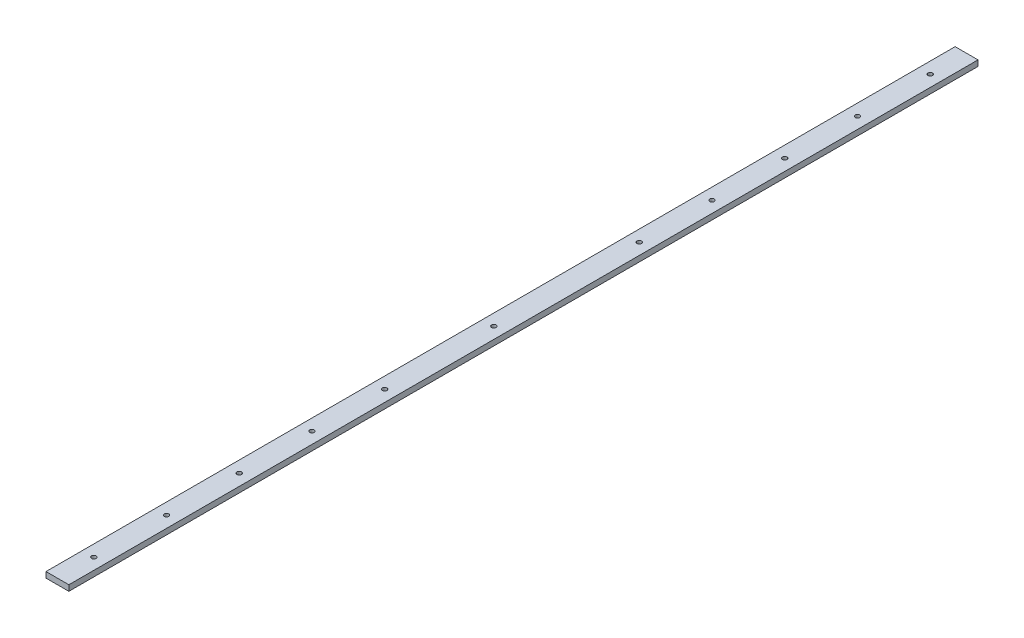
from build123d import *

# Parameters (mm, degrees)
SKETCH1_W                       = 12.7
SKETCH1_H                       = 505
BOSS_EXTRUDE1_DEPTH             = 3.175
TAP_DRILL_FOR_M3X0_5_TAP3_D     = 2.5
TAP_DRILL_FOR_M3X0_5_TAP3_DEPTH = 11.68
TAP_DRILL_FOR_M3X0_5_TAP3_TIP   = 0.751075774


with BuildPart() as part:
    # Sketch1 → Boss-Extrude1 (new body)
    with BuildSketch(Plane(origin=(0, 0, 0), x_dir=(1, 0, 0), z_dir=(0, 1, 0))):
        with Locations((6.35, 252.5)):
            Rectangle(SKETCH1_W, SKETCH1_H)
    extrude(amount=BOSS_EXTRUDE1_DEPTH)

    # Tap Drill for M3x0.5 Tap3
    with Locations(Plane(origin=(0, 3.175, 0), x_dir=(1, 0, 0), z_dir=(0, 1, 0))):
        with Locations((6.35, 20.2), (6.35, 60.6), (6.35, 101), (6.35, 141.4), (6.35, 181.8), (6.35, 242.4), (6.35, 323.2), (6.35, 363.6), (6.35, 404), (6.35, 444.4), (6.35, 484.8)):
            Hole(TAP_DRILL_FOR_M3X0_5_TAP3_D / 2, depth=TAP_DRILL_FOR_M3X0_5_TAP3_DEPTH)
            with Locations((0, 0, -(TAP_DRILL_FOR_M3X0_5_TAP3_DEPTH + TAP_DRILL_FOR_M3X0_5_TAP3_TIP / 2))):  # 118° drill point
                Cone(0, TAP_DRILL_FOR_M3X0_5_TAP3_D / 2, TAP_DRILL_FOR_M3X0_5_TAP3_TIP, mode=Mode.SUBTRACT)


solid = part.part
